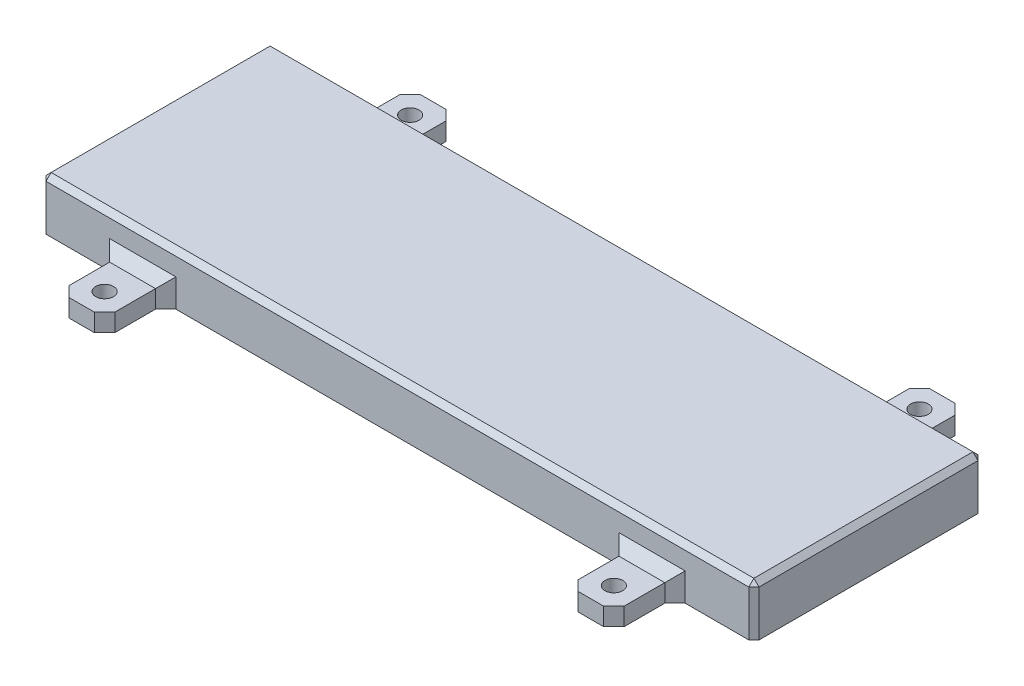
from build123d import *

# Parameters (mm, degrees)
CROQUIS1_W              = 140
CROQUIS1_H              = 45
CROQUIS1_W_2            = 136
CROQUIS1_H_2            = 41
SALIENTE_EXTRUIR1_DEPTH = 10
CROQUIS2_W              = 140
CROQUIS2_H              = 45
SALIENTE_EXTRUIR2_DEPTH = 2
CHAFL_N1_SIZE           = 1
CROQUIS3_W              = 9
CROQUIS3_H              = 12
CROQUIS3_R              = 1.75
SALIENTE_EXTRUIR3_DEPTH = 3.5
CHAFL_N2_SIZE           = 2
CROQUIS4_W              = 20
CROQUIS4_H              = 7.5
CORTAR_EXTRUIR1_DEPTH   = 3.5


with BuildPart() as part:
    # Croquis1 → Saliente-Extruir1 (new body)
    with BuildSketch(Plane(origin=(0, 0, 0), x_dir=(1, 0, 0), z_dir=(0, 1, 0))):
        Rectangle(CROQUIS1_W, CROQUIS1_H)
        Rectangle(CROQUIS1_W_2, CROQUIS1_H_2, mode=Mode.SUBTRACT)
    extrude(amount=SALIENTE_EXTRUIR1_DEPTH)

    # Croquis2 → Saliente-Extruir2 (add)
    with BuildSketch(Plane(origin=(0, 10, 0), x_dir=(1, 0, 0), z_dir=(0, 1, 0))):
        Rectangle(CROQUIS2_W, CROQUIS2_H)
    extrude(amount=-SALIENTE_EXTRUIR2_DEPTH)

    # Chaflán1
    chafl_n1_edges = [part.edges().sort_by_distance(p)[0] for p in [
        (-70, 10, 0),
        (0, 10, 22.5),
        (70, 10, 0),
        (70, 5, 22.5),
        (-70, 5, 22.5),
        (-70, 5, -22.5),
        (70, 5, -22.5),
        (0, 10, -22.5),
    ]]
    chamfer(chafl_n1_edges, length=CHAFL_N1_SIZE)

    # Croquis3 → Saliente-Extruir3 (add)
    with BuildSketch(Plane(origin=(0, 0, 0), x_dir=(1, 0, 0), z_dir=(0, 1, 0))):
        with Locations((-50, 28.5)):
            Rectangle(CROQUIS3_W, CROQUIS3_H)
        with Locations((-50, 30)):
            Circle(CROQUIS3_R, mode=Mode.SUBTRACT)
        with Locations((50, 28.5)):
            Rectangle(CROQUIS3_W, CROQUIS3_H)
        with Locations((50, 30)):
            Circle(CROQUIS3_R, mode=Mode.SUBTRACT)
        with Locations((-50, -28.5)):
            Rectangle(CROQUIS3_W, CROQUIS3_H)
        with Locations((-50, -30)):
            Circle(CROQUIS3_R, mode=Mode.SUBTRACT)
        with Locations((50, -28.5)):
            Rectangle(CROQUIS3_W, CROQUIS3_H)
        with Locations((50, -30)):
            Circle(CROQUIS3_R, mode=Mode.SUBTRACT)
    extrude(amount=SALIENTE_EXTRUIR3_DEPTH)

    # Chaflán2
    chafl_n2_edges = [part.edges().sort_by_distance(p)[0] for p in [
        (-50, 3.5, 22.5),
        (-54.5, 1.75, 22.5),
        (-54.5, 1.75, 34.5),
        (-45.5, 1.75, 34.5),
        (-45.5, 1.75, 22.5),
        (50, 3.5, 22.5),
        (45.5, 1.75, 22.5),
        (45.5, 1.75, 34.5),
        (54.5, 1.75, 34.5),
        (54.5, 1.75, 22.5),
        (-50, 3.5, -22.5),
        (-54.5, 1.75, -34.5),
        (-54.5, 1.75, -22.5),
        (-45.5, 1.75, -22.5),
        (-45.5, 1.75, -34.5),
        (50, 3.5, -22.5),
        (45.5, 1.75, -34.5),
        (45.5, 1.75, -22.5),
        (54.5, 1.75, -22.5),
        (54.5, 1.75, -34.5),
    ]]
    chamfer(chafl_n2_edges, length=CHAFL_N2_SIZE)

    # Croquis4 → Cortar-Extruir1 (cut)
    with BuildSketch(Plane.ZY.offset(70)):
        with Locations((0, 3.75)):
            Rectangle(CROQUIS4_W, CROQUIS4_H)
    extrude(amount=-CORTAR_EXTRUIR1_DEPTH, mode=Mode.SUBTRACT)


solid = part.part
